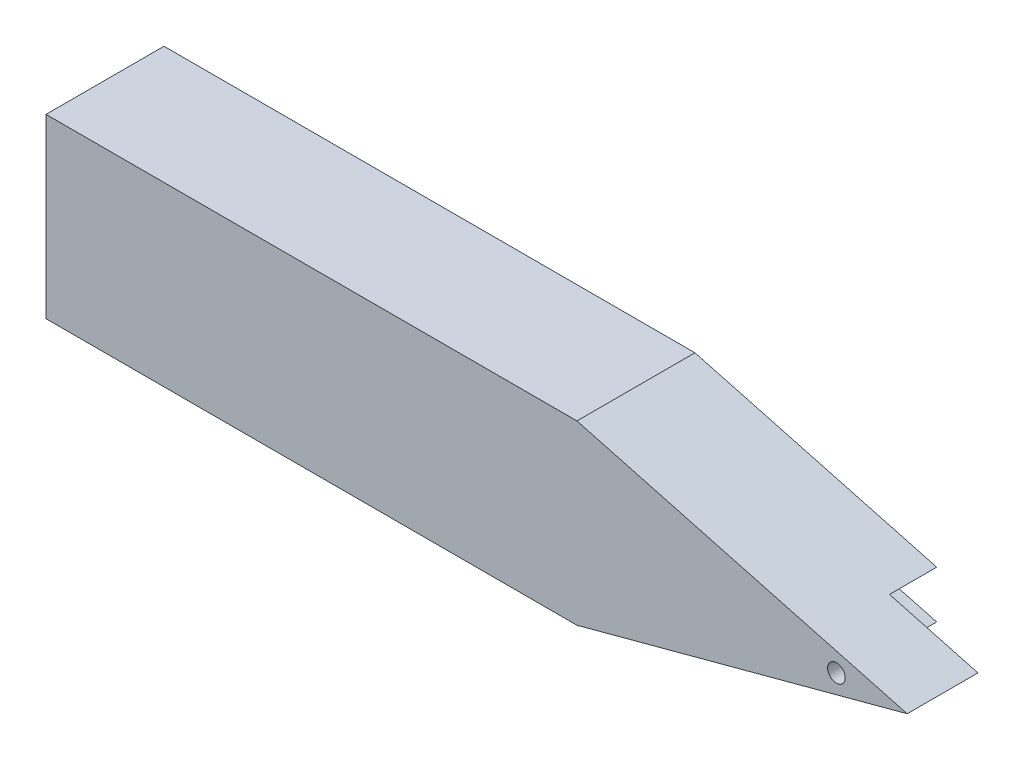
from build123d import *

# Parameters (mm, degrees)
EXTRUDE_1_DEPTH     = 20
CUT_EXTRUDE_1_DEPTH = 8
SKETCH_4_R          = 1.5
CUT_EXTRUDE_2_DEPTH = 13


with BuildPart() as part:
    # 草图1 → 凸台-拉伸1 (new body)
    with BuildSketch(Plane.XY):
        Polygon((47.5, 15), (103.480762114, 0), (47.5, -15), (-42.5, -15), (-42.5, 15), align=None)
    extrude(amount=EXTRUDE_1_DEPTH)

    # 草图2 → 切除-拉伸1 (cut)
    with BuildSketch(Plane(origin=(0, 0, 0), x_dir=(-1, 0, 0), z_dir=(0, 0, -1))):
        Polygon((-88.480762114, 4.019237886), (-73.480762114, 0), (-88.480762114, -4.019237886), (-103.480762114, 0), align=None)
    extrude(amount=-CUT_EXTRUDE_1_DEPTH, mode=Mode.SUBTRACT)

    # 草图4 → 切除-拉伸2 (cut, through all)
    with BuildSketch(Plane(origin=(0, 0, 8), x_dir=(-1, 0, 0), z_dir=(0, 0, -1))):
        with Locations((-91.480762114, 0)):
            Circle(SKETCH_4_R)
    extrude(amount=-CUT_EXTRUDE_2_DEPTH, mode=Mode.SUBTRACT)


solid = part.part
